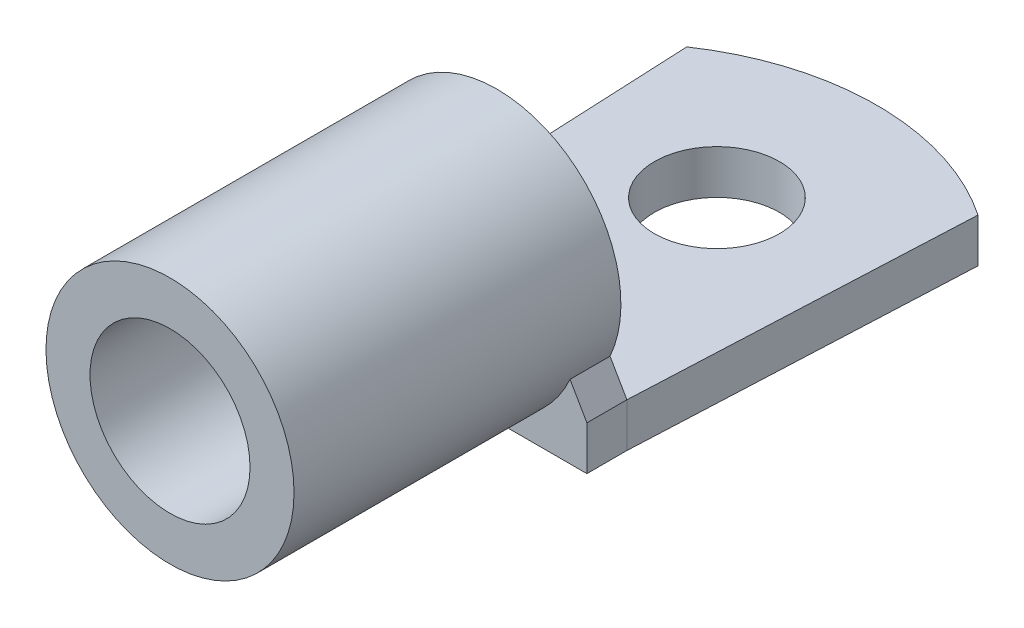
from build123d import *

# Parameters (mm, degrees)
SKETCH1_R                   = 3.96875
LUG_DEPTH                   = 2.794
SKETCH2_R                   = 7.874
SKETCH2_R_2                 = 5.08
CRIMP_SOCKET_DEPTH          = 20.7518
LUG_SOCKET_CONNECTION_DEPTH = 2.54


with BuildPart() as part:
    # Sketch1 → Lug (new body)
    with BuildSketch(Plane(origin=(0, 0, 0), x_dir=(1, 0, 0), z_dir=(0, 1, 0))):
        with BuildLine():
            Line((-9.2456, 7.328412943), (-8.255, -13.97))
            Line((-8.255, -13.97), (8.255, -13.97))
            Line((8.255, -13.97), (9.2456, 7.328412943))
            ThreePointArc((9.2456, 7.328412943), (0, 10.16), (-9.2456, 7.328412943))
        make_face()
        Circle(SKETCH1_R, mode=Mode.SUBTRACT)
    extrude(amount=LUG_DEPTH)

    # Sketch2 → Crimp Socket (add)
    with BuildSketch(Plane.XY.offset(13.97)):
        with Locations((0, 7.874)):
            Circle(SKETCH2_R)
        with Locations((0, 7.874)):
            Circle(SKETCH2_R_2, mode=Mode.SUBTRACT)
    extrude(amount=CRIMP_SOCKET_DEPTH)

    # Sketch3 → Lug Socket Connection (add)
    with BuildSketch(Plane.XY.offset(13.97)):
        with BuildLine():
            Line((8.255, 2.794), (7.183591408, 4.649734117))
            ThreePointArc((7.183591408, 4.649734117), (0, 15.748), (-7.183591408, 4.649734117))
            Line((-7.183591408, 4.649734117), (-8.255, 2.794))
            Line((-8.255, 2.794), (-8.255, 0))
            Line((-8.255, 0), (8.255, 0))
            Line((8.255, 0), (8.255, 2.794))
        make_face()
    extrude(amount=LUG_SOCKET_CONNECTION_DEPTH)


solid = part.part
